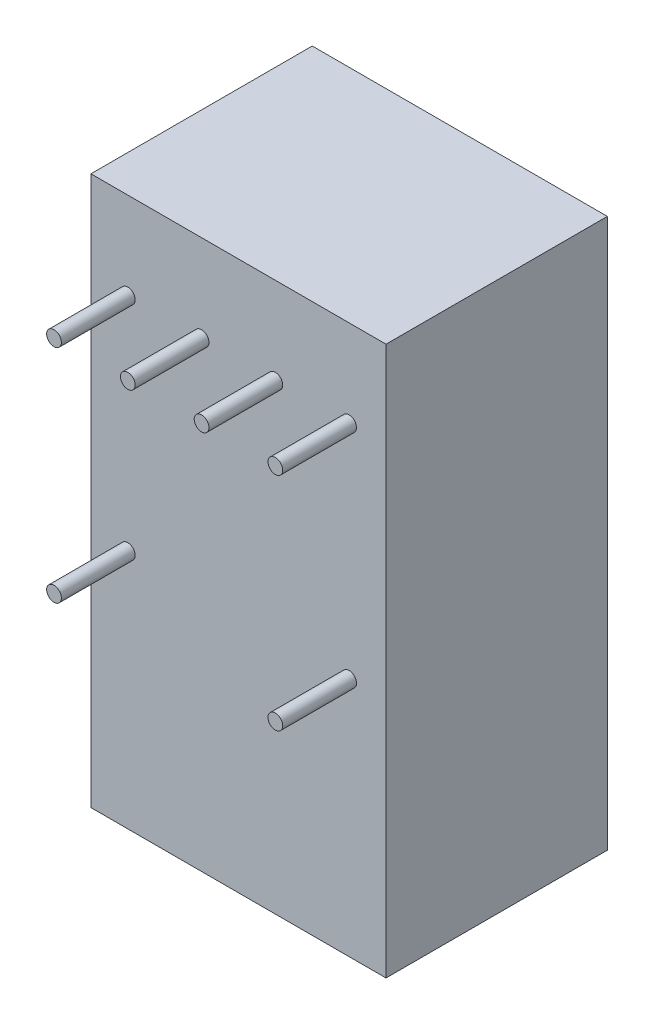
from build123d import *

# Parameters (mm, degrees)
SKETCH1_R        = 0.254
EXTRUDE1_DEPTH   = 2.54
EXTRUDE1_2_DEPTH = 2.54
EXTRUDE1_3_DEPTH = 2.54
EXTRUDE1_4_DEPTH = 2.54
EXTRUDE1_5_DEPTH = 2.54
EXTRUDE1_6_DEPTH = 2.54
SKETCH2_W        = 10.16
SKETCH2_H        = 18.8976
EXTRUDE2_DEPTH   = 7.62


with BuildPart() as part:
    # Sketch1 → Extrude1 (new body)
    with BuildSketch(Plane.XY):
        Circle(SKETCH1_R)
    extrude(amount=EXTRUDE1_DEPTH)



with BuildPart() as body_2:
    # Sketch1 → Extrude1 2 (new body)
    with BuildSketch(Plane.XY):
        with Locations((2.54, 0)):
            Circle(SKETCH1_R)
    extrude(amount=EXTRUDE1_2_DEPTH)


with BuildPart() as body_3:
    # Sketch1 → Extrude1 3 (new body)
    with BuildSketch(Plane.XY):
        with Locations((5.08, 0)):
            Circle(SKETCH1_R)
    extrude(amount=EXTRUDE1_3_DEPTH)


with BuildPart() as body_4:
    # Sketch1 → Extrude1 4 (new body)
    with BuildSketch(Plane.XY):
        with Locations((7.62, 0)):
            Circle(SKETCH1_R)
    extrude(amount=EXTRUDE1_4_DEPTH)


with BuildPart() as body_5:
    # Sketch1 → Extrude1 5 (new body)
    with BuildSketch(Plane.XY):
        with Locations((0, -7.62)):
            Circle(SKETCH1_R)
    extrude(amount=EXTRUDE1_5_DEPTH)


with BuildPart() as body_6:
    # Sketch1 → Extrude1 6 (new body)
    with BuildSketch(Plane.XY):
        with Locations((7.62, -7.62)):
            Circle(SKETCH1_R)
    extrude(amount=EXTRUDE1_6_DEPTH)


with BuildPart() as part_1:
    add(part.part)

    add(body_2.part)  # Extrude2 merges body 2

    add(body_3.part)  # Extrude2 merges body 3

    add(body_4.part)  # Extrude2 merges body 4

    add(body_5.part)  # Extrude2 merges body 5

    add(body_6.part)  # Extrude2 merges body 6
    # Sketch2 → Extrude2 (add)
    with BuildSketch(Plane(origin=(0, 0, 0), x_dir=(-1, 0, 0), z_dir=(0, 0, -1))):
        with Locations((-3.81, -6.4516)):
            Rectangle(SKETCH2_W, SKETCH2_H)
    extrude(amount=EXTRUDE2_DEPTH)


solid = part_1.part
